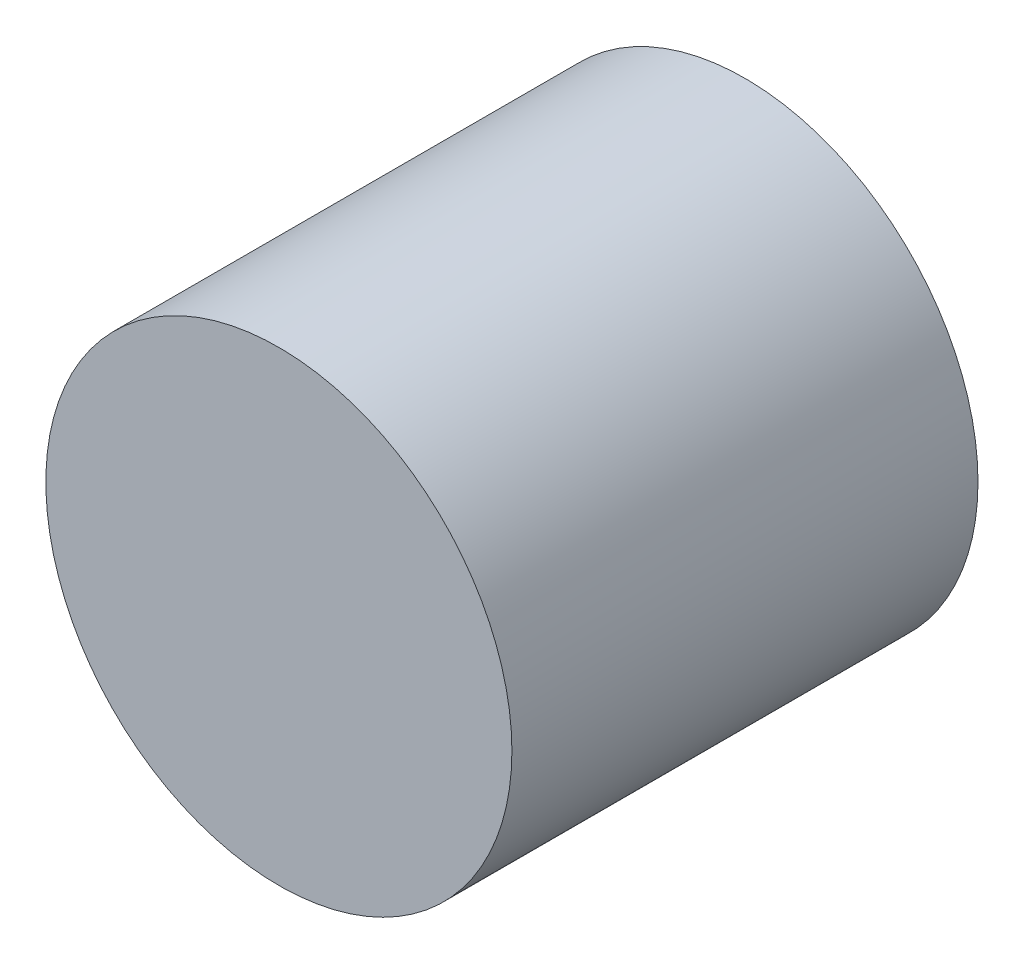
from build123d import *

# Parameters (mm, degrees)
SKETCH1_R           = 8.5
BOSS_EXTRUDE1_DEPTH = 17


with BuildPart() as part:
    # Sketch1 → Boss-Extrude1 (new body)
    with BuildSketch(Plane.XY):
        Circle(SKETCH1_R)
    extrude(amount=BOSS_EXTRUDE1_DEPTH)


solid = part.part
